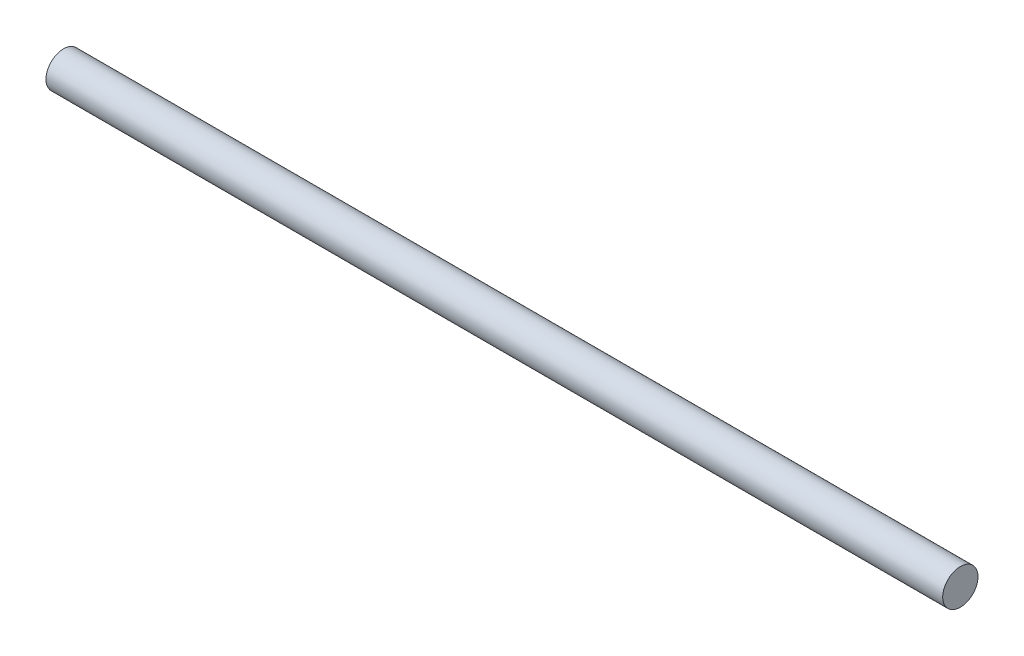
from build123d import *

# Parameters (mm, degrees)
SKETCH1_R           = 2
BOSS_EXTRUDE1_DEPTH = 101.6


with BuildPart() as part:
    # Sketch1 → Boss-Extrude1 (new body)
    with BuildSketch(Plane(origin=(0, 0, 0), x_dir=(0, 0, -1), z_dir=(1, 0, 0))):
        Circle(SKETCH1_R)
    extrude(amount=BOSS_EXTRUDE1_DEPTH)


solid = part.part
